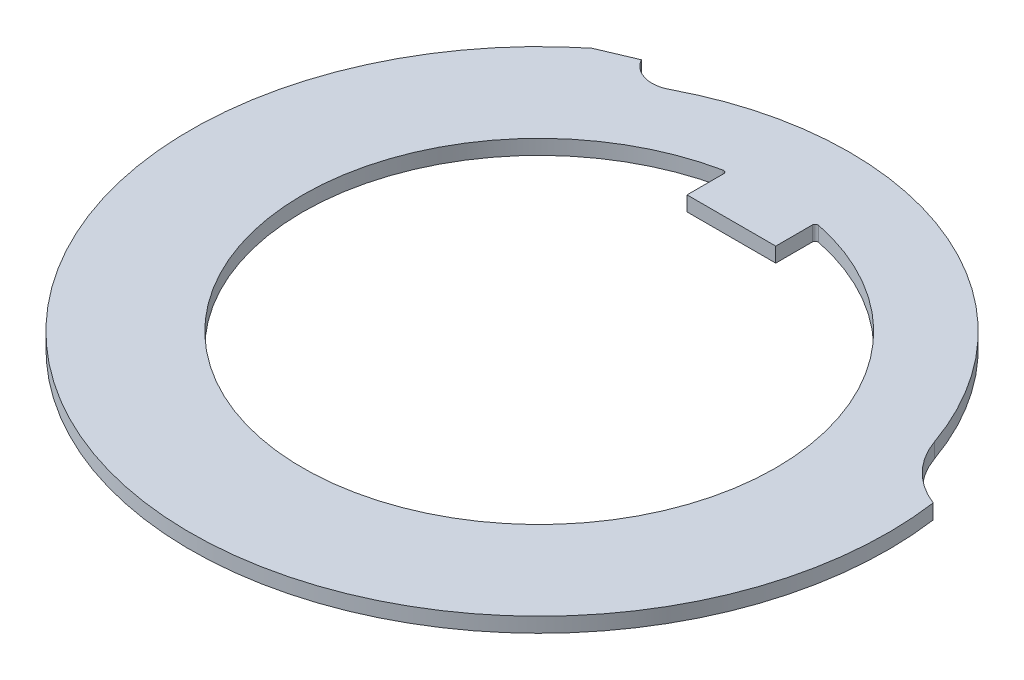
from build123d import *

# Parameters (mm, degrees)
BOSS_EXTRUDE1_DEPTH = 0.5
FILLET1_R           = 0.1


with BuildPart() as part:
    # Sketch1 → Boss-Extrude1 (new body)
    with BuildSketch(Plane(origin=(0, 0, 0), x_dir=(1, 0, 0), z_dir=(0, 1, 0))):
        with BuildLine():
            Line((-7.405833782, 9.18660035), (-6.230046676, 9.685692366))
            ThreePointArc((-6.230046676, 9.685692366), (-5.641408049, 9.216396236), (-4.892259398, 9.29062958))
            ThreePointArc((-4.892259398, 9.29062958), (3.847452899, 9.769703485), (9.913592586, 3.459867344))
            ThreePointArc((9.913592586, 3.459867344), (10.597684768, 2.354472244), (11.685163211, 1.642242591))
            ThreePointArc((11.685163211, 1.642242591), (2.904608858, -11.436924735), (-11.052731833, -4.132447099))
            ThreePointArc((-11.052731833, -4.132447099), (-11.381077163, 3.116261), (-7.405833782, 9.18660035))
        make_face()
        with BuildLine():
            Line((-1.5, 6.5), (1.5, 6.5))
            Line((1.5, 6.5), (1.5, 7.858116823))
            ThreePointArc((1.5, 7.858116823), (0, -8), (-1.5, 7.858116823))
            Line((-1.5, 7.858116823), (-1.5, 6.5))
        make_face(mode=Mode.SUBTRACT)
    extrude(amount=BOSS_EXTRUDE1_DEPTH)

    # Fillet1
    fillet1_edges = [part.edges().sort_by_distance(p)[0] for p in [
        (-1.5, 0.25, -7.858116823),
        (1.5, 0.25, -7.858116823),
    ]]
    fillet(fillet1_edges, radius=FILLET1_R)


solid = part.part
